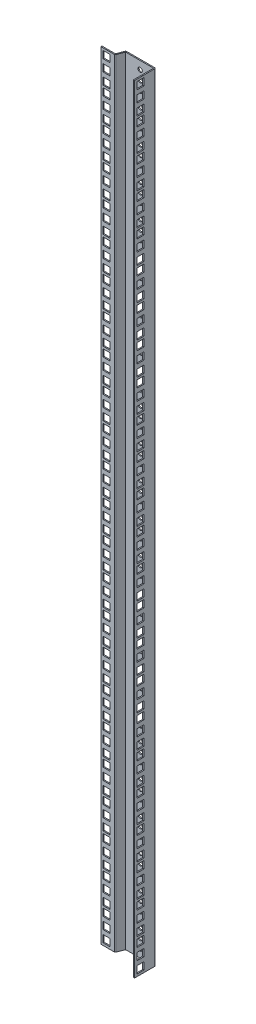
from build123d import *

# Parameters (mm, degrees)
EXTRUDE_1_DEPTH          = 1070
SKETCH_2_R               = 3
SKETCH_2_W               = 9.6
SKETCH_2_H               = 9.898426353
SKETCH_2_H_2             = 9.898426354
CUT_EXTRUDE_2_DEPTH      = 39
CUT_EXTRUDE_2_DEPTH_BACK = 84
SKETCH_4_W               = 9.6
SKETCH_4_H               = 9.898426353
SKETCH_4_H_2             = 9.898426354
CUT_EXTRUDE_3_DEPTH      = 26
CUT_EXTRUDE_3_DEPTH_BACK = 21


with BuildPart() as part:
    # 草图1 → 凸台-拉伸1 (new body)
    with BuildSketch(Plane(origin=(0, 0, 0), x_dir=(1, 0, 0), z_dir=(0, 1, 0))):
        with BuildLine():
            Line((-1.547342022, -0.717636551), (16.952657978, -0.71760263))
            ThreePointArc((16.952657978, -0.71760263), (17.80572902, -0.451398293), (18.356004933, 0.252726251))
            Line((18.356004933, 0.252726251), (21.952594506, 9.782387404))
            Line((21.952594506, 9.782387404), (60.452594506, 9.782387404))
            Line((60.452594506, 9.782387404), (60.452594506, -17.717612596))
            Line((60.452594506, -17.717612596), (61.952594506, -17.717612596))
            Line((61.952594506, -17.717612596), (61.952594506, 9.782387404))
            ThreePointArc((61.952594506, 9.782387404), (61.513254678, 10.843047575), (60.452594506, 11.282387404))
            Line((60.452594506, 11.282387404), (21.952594506, 11.282387404))
            ThreePointArc((21.952594506, 11.282387404), (21.099502117, 11.016175625), (20.549214051, 10.312031905))
            Line((20.549214051, 10.312031905), (16.952657978, 0.782363449))
            Line((16.952657978, 0.782363449), (-1.547342022, 0.782363449))
            Line((-1.547342022, 0.782363449), (-1.547342022, -0.717636551))
        make_face()
    extrude(amount=EXTRUDE_1_DEPTH)

    # 草图2 → 切除-拉伸2 (cut, two sides)
    with BuildSketch(Plane.XY.offset(-9.782387404)) as cut_extrude_2_sk:
        with Locations((41.952594506, 1046.275)):
            Circle(SKETCH_2_R)
        with Locations((41.952594506, 1058.775)):
            Circle(SKETCH_2_R)
        with Locations((41.952594506, 1033.775)):
            Circle(SKETCH_2_R)
        with Locations((41.952594506, 1001.825)):
            Circle(SKETCH_2_R)
        with Locations((41.952594506, 1014.325)):
            Circle(SKETCH_2_R)
        with Locations((41.952594506, 989.325)):
            Circle(SKETCH_2_R)
        with Locations((41.952594506, 957.375)):
            Circle(SKETCH_2_R)
        with Locations((41.952594506, 969.875)):
            Circle(SKETCH_2_R)
        with Locations((41.952594506, 944.875)):
            Circle(SKETCH_2_R)
        with Locations((41.952594506, 912.925)):
            Circle(SKETCH_2_R)
        with Locations((41.952594506, 925.425)):
            Circle(SKETCH_2_R)
        with Locations((41.952594506, 900.425)):
            Circle(SKETCH_2_R)
        with Locations((41.952594506, 868.475)):
            Circle(SKETCH_2_R)
        with Locations((41.952594506, 880.975)):
            Circle(SKETCH_2_R)
        with Locations((41.952594506, 855.975)):
            Circle(SKETCH_2_R)
        with Locations((41.952594506, 646.225)):
            Circle(SKETCH_2_R)
        with Locations((41.952594506, 658.725)):
            Circle(SKETCH_2_R)
        with Locations((41.952594506, 633.725)):
            Circle(SKETCH_2_R)
        with Locations((41.952594506, 601.775)):
            Circle(SKETCH_2_R)
        with Locations((41.952594506, 614.275)):
            Circle(SKETCH_2_R)
        with Locations((41.952594506, 589.275)):
            Circle(SKETCH_2_R)
        with Locations((41.952594506, 557.325)):
            Circle(SKETCH_2_R)
        with Locations((41.952594506, 569.825)):
            Circle(SKETCH_2_R)
        with Locations((41.952594506, 544.825)):
            Circle(SKETCH_2_R)
        with Locations((41.952594506, 512.875)):
            Circle(SKETCH_2_R)
        with Locations((41.952594506, 525.375)):
            Circle(SKETCH_2_R)
        with Locations((41.952594506, 500.375)):
            Circle(SKETCH_2_R)
        with Locations((41.952594506, 468.425)):
            Circle(SKETCH_2_R)
        with Locations((41.952594506, 480.925)):
            Circle(SKETCH_2_R)
        with Locations((41.952594506, 455.925)):
            Circle(SKETCH_2_R)
        with Locations((41.952594506, 246.175)):
            Circle(SKETCH_2_R)
        with Locations((41.952594506, 258.675)):
            Circle(SKETCH_2_R)
        with Locations((41.952594506, 233.675)):
            Circle(SKETCH_2_R)
        with Locations((41.952594506, 201.725)):
            Circle(SKETCH_2_R)
        with Locations((41.952594506, 214.225)):
            Circle(SKETCH_2_R)
        with Locations((41.952594506, 189.225)):
            Circle(SKETCH_2_R)
        with Locations((41.952594506, 157.275)):
            Circle(SKETCH_2_R)
        with Locations((41.952594506, 169.775)):
            Circle(SKETCH_2_R)
        with Locations((41.952594506, 144.775)):
            Circle(SKETCH_2_R)
        with Locations((41.952594506, 112.825)):
            Circle(SKETCH_2_R)
        with Locations((41.952594506, 125.325)):
            Circle(SKETCH_2_R)
        with Locations((41.952594506, 100.325)):
            Circle(SKETCH_2_R)
        with Locations((41.952594506, 68.375)):
            Circle(SKETCH_2_R)
        with Locations((41.952594506, 80.875)):
            Circle(SKETCH_2_R)
        with Locations((41.952594506, 55.875)):
            Circle(SKETCH_2_R)
        with Locations((41.952594506, 23.925)):
            Circle(SKETCH_2_R)
        with Locations((41.952594506, 36.425)):
            Circle(SKETCH_2_R)
        with Locations((41.952594506, 11.425)):
            Circle(SKETCH_2_R)
        with Locations((6.252657978, 662.000786823)):
            Rectangle(SKETCH_2_W, SKETCH_2_H)
        with Locations((6.252657978, 1062.050786823)):
            Rectangle(SKETCH_2_W, SKETCH_2_H)
        with Locations((6.252657978, 1017.600786824)):
            Rectangle(SKETCH_2_W, SKETCH_2_H)
        with Locations((6.252657978, 617.550786823)):
            Rectangle(SKETCH_2_W, SKETCH_2_H)
        with Locations((6.252657978, 1030.499213177)):
            Rectangle(SKETCH_2_W, SKETCH_2_H)
        with Locations((6.252657978, 1046.275)):
            Rectangle(SKETCH_2_W, SKETCH_2_H_2)
        with Locations((6.252657978, 884.250786823)):
            Rectangle(SKETCH_2_W, SKETCH_2_H)
        with Locations((6.252657978, 986.049213176)):
            Rectangle(SKETCH_2_W, SKETCH_2_H)
        with Locations((6.252657978, 1001.825)):
            Rectangle(SKETCH_2_W, SKETCH_2_H_2)
        with Locations((6.252657978, 973.150786824)):
            Rectangle(SKETCH_2_W, SKETCH_2_H)
        with Locations((6.252657978, 928.700786824)):
            Rectangle(SKETCH_2_W, SKETCH_2_H)
        with Locations((6.252657978, 941.599213177)):
            Rectangle(SKETCH_2_W, SKETCH_2_H)
        with Locations((6.252657978, 957.375)):
            Rectangle(SKETCH_2_W, SKETCH_2_H_2)
        with Locations((6.252657978, 897.149213177)):
            Rectangle(SKETCH_2_W, SKETCH_2_H)
        with Locations((6.252657978, 912.925)):
            Rectangle(SKETCH_2_W, SKETCH_2_H_2)
        with Locations((6.252657978, 839.800786823)):
            Rectangle(SKETCH_2_W, SKETCH_2_H)
        with Locations((6.252657978, 852.699213177)):
            Rectangle(SKETCH_2_W, SKETCH_2_H)
        with Locations((6.252657978, 868.475)):
            Rectangle(SKETCH_2_W, SKETCH_2_H_2)
        with Locations((6.252657978, 808.249213177)):
            Rectangle(SKETCH_2_W, SKETCH_2_H)
        with Locations((6.252657978, 824.025)):
            Rectangle(SKETCH_2_W, SKETCH_2_H_2)
        with BuildLine():
            Line((33.962594506, 832.025), (33.962594506, 816.025))
            ThreePointArc((33.962594506, 816.025), (41.952594506, 808.035), (49.942594506, 816.025))
            Line((49.942594506, 816.025), (49.942594506, 832.025))
            ThreePointArc((49.942594506, 832.025), (41.952594506, 840.015), (33.962594506, 832.025))
        make_face()
        with Locations((6.252657978, 795.350786824)):
            Rectangle(SKETCH_2_W, SKETCH_2_H)
        with Locations((6.252657978, 763.799213176)):
            Rectangle(SKETCH_2_W, SKETCH_2_H)
        with Locations((6.252657978, 779.575)):
            Rectangle(SKETCH_2_W, SKETCH_2_H_2)
        with BuildLine():
            Line((33.962594506, 787.575), (33.962594506, 771.575))
            ThreePointArc((33.962594506, 771.575), (41.952594506, 763.585), (49.942594506, 771.575))
            Line((49.942594506, 771.575), (49.942594506, 787.575))
            ThreePointArc((49.942594506, 787.575), (41.952594506, 795.565), (33.962594506, 787.575))
        make_face()
        with Locations((6.252657978, 750.900786824)):
            Rectangle(SKETCH_2_W, SKETCH_2_H)
        with Locations((6.252657978, 719.349213177)):
            Rectangle(SKETCH_2_W, SKETCH_2_H)
        with Locations((6.252657978, 735.125)):
            Rectangle(SKETCH_2_W, SKETCH_2_H_2)
        with BuildLine():
            Line((33.962594506, 743.125), (33.962594506, 727.125))
            ThreePointArc((33.962594506, 727.125), (41.952594506, 719.135), (49.942594506, 727.125))
            Line((49.942594506, 727.125), (49.942594506, 743.125))
            ThreePointArc((49.942594506, 743.125), (41.952594506, 751.115), (33.962594506, 743.125))
        make_face()
        with Locations((6.252657978, 706.450786824)):
            Rectangle(SKETCH_2_W, SKETCH_2_H)
        with Locations((6.252657978, 674.899213177)):
            Rectangle(SKETCH_2_W, SKETCH_2_H)
        with Locations((6.252657978, 690.675)):
            Rectangle(SKETCH_2_W, SKETCH_2_H_2)
        with BuildLine():
            Line((33.962594506, 698.675), (33.962594506, 682.675))
            ThreePointArc((33.962594506, 682.675), (41.952594506, 674.685), (49.942594506, 682.675))
            Line((49.942594506, 682.675), (49.942594506, 698.675))
            ThreePointArc((49.942594506, 698.675), (41.952594506, 706.665), (33.962594506, 698.675))
        make_face()
        with Locations((6.252657978, 630.449213177)):
            Rectangle(SKETCH_2_W, SKETCH_2_H)
        with Locations((6.252657978, 646.225)):
            Rectangle(SKETCH_2_W, SKETCH_2_H_2)
        with Locations((6.252657978, 484.200786824)):
            Rectangle(SKETCH_2_W, SKETCH_2_H)
        with Locations((6.252657978, 585.999213177)):
            Rectangle(SKETCH_2_W, SKETCH_2_H)
        with Locations((6.252657978, 601.775)):
            Rectangle(SKETCH_2_W, SKETCH_2_H_2)
        with Locations((6.252657978, 573.100786824)):
            Rectangle(SKETCH_2_W, SKETCH_2_H)
        with Locations((6.252657978, 528.650786824)):
            Rectangle(SKETCH_2_W, SKETCH_2_H)
        with Locations((6.252657978, 541.549213176)):
            Rectangle(SKETCH_2_W, SKETCH_2_H)
        with Locations((6.252657978, 557.325)):
            Rectangle(SKETCH_2_W, SKETCH_2_H_2)
        with Locations((6.252657978, 497.099213177)):
            Rectangle(SKETCH_2_W, SKETCH_2_H)
        with Locations((6.252657978, 512.875)):
            Rectangle(SKETCH_2_W, SKETCH_2_H_2)
        with Locations((6.252657978, 439.750786824)):
            Rectangle(SKETCH_2_W, SKETCH_2_H)
        with Locations((6.252657978, 452.649213177)):
            Rectangle(SKETCH_2_W, SKETCH_2_H)
        with Locations((6.252657978, 468.425)):
            Rectangle(SKETCH_2_W, SKETCH_2_H_2)
        with Locations((6.252657978, 408.199213177)):
            Rectangle(SKETCH_2_W, SKETCH_2_H)
        with Locations((6.252657978, 423.975)):
            Rectangle(SKETCH_2_W, SKETCH_2_H_2)
        with BuildLine():
            Line((33.962594506, 431.975), (33.962594506, 415.975))
            ThreePointArc((33.962594506, 415.975), (41.952594506, 407.985), (49.942594506, 415.975))
            Line((49.942594506, 415.975), (49.942594506, 431.975))
            ThreePointArc((49.942594506, 431.975), (41.952594506, 439.965), (33.962594506, 431.975))
        make_face()
        with Locations((6.252657978, 395.300786824)):
            Rectangle(SKETCH_2_W, SKETCH_2_H)
        with Locations((6.252657978, 363.749213177)):
            Rectangle(SKETCH_2_W, SKETCH_2_H)
        with Locations((6.252657978, 379.525)):
            Rectangle(SKETCH_2_W, SKETCH_2_H_2)
        with BuildLine():
            Line((33.962594506, 387.525), (33.962594506, 371.525))
            ThreePointArc((33.962594506, 371.525), (41.952594506, 363.535), (49.942594506, 371.525))
            Line((49.942594506, 371.525), (49.942594506, 387.525))
            ThreePointArc((49.942594506, 387.525), (41.952594506, 395.515), (33.962594506, 387.525))
        make_face()
        with Locations((6.252657978, 350.850786824)):
            Rectangle(SKETCH_2_W, SKETCH_2_H)
        with Locations((6.252657978, 319.299213177)):
            Rectangle(SKETCH_2_W, SKETCH_2_H)
        with Locations((6.252657978, 335.075)):
            Rectangle(SKETCH_2_W, SKETCH_2_H_2)
        with BuildLine():
            Line((33.962594506, 343.075), (33.962594506, 327.075))
            ThreePointArc((33.962594506, 327.075), (41.952594506, 319.085), (49.942594506, 327.075))
            Line((49.942594506, 327.075), (49.942594506, 343.075))
            ThreePointArc((49.942594506, 343.075), (41.952594506, 351.065), (33.962594506, 343.075))
        make_face()
        with Locations((6.252657978, 306.400786824)):
            Rectangle(SKETCH_2_W, SKETCH_2_H)
        with Locations((6.252657978, 274.849213177)):
            Rectangle(SKETCH_2_W, SKETCH_2_H)
        with Locations((6.252657978, 290.625)):
            Rectangle(SKETCH_2_W, SKETCH_2_H_2)
        with BuildLine():
            Line((33.962594506, 298.625), (33.962594506, 282.625))
            ThreePointArc((33.962594506, 282.625), (41.952594506, 274.635), (49.942594506, 282.625))
            Line((49.942594506, 282.625), (49.942594506, 298.625))
            ThreePointArc((49.942594506, 298.625), (41.952594506, 306.615), (33.962594506, 298.625))
        make_face()
        with Locations((6.252657978, 261.950786824)):
            Rectangle(SKETCH_2_W, SKETCH_2_H)
        with Locations((6.252657978, 217.500786824)):
            Rectangle(SKETCH_2_W, SKETCH_2_H)
        with Locations((6.252657978, 230.399213177)):
            Rectangle(SKETCH_2_W, SKETCH_2_H)
        with Locations((6.252657978, 246.175)):
            Rectangle(SKETCH_2_W, SKETCH_2_H_2)
        with Locations((6.252657978, 84.150786823)):
            Rectangle(SKETCH_2_W, SKETCH_2_H)
        with Locations((6.252657978, 185.949213176)):
            Rectangle(SKETCH_2_W, SKETCH_2_H)
        with Locations((6.252657978, 201.725)):
            Rectangle(SKETCH_2_W, SKETCH_2_H_2)
        with Locations((6.252657978, 173.050786824)):
            Rectangle(SKETCH_2_W, SKETCH_2_H)
        with Locations((6.252657978, 128.600786824)):
            Rectangle(SKETCH_2_W, SKETCH_2_H)
        with Locations((6.252657978, 141.499213177)):
            Rectangle(SKETCH_2_W, SKETCH_2_H)
        with Locations((6.252657978, 157.275)):
            Rectangle(SKETCH_2_W, SKETCH_2_H_2)
        with Locations((6.252657978, 97.049213177)):
            Rectangle(SKETCH_2_W, SKETCH_2_H)
        with Locations((6.252657978, 112.825)):
            Rectangle(SKETCH_2_W, SKETCH_2_H_2)
        with Locations((6.252657978, 39.700786824)):
            Rectangle(SKETCH_2_W, SKETCH_2_H)
        with Locations((6.252657978, 52.599213177)):
            Rectangle(SKETCH_2_W, SKETCH_2_H)
        with Locations((6.252657978, 68.375)):
            Rectangle(SKETCH_2_W, SKETCH_2_H_2)
        with Locations((6.252657978, 8.149213176)):
            Rectangle(SKETCH_2_W, SKETCH_2_H)
        with Locations((6.252657978, 23.925)):
            Rectangle(SKETCH_2_W, SKETCH_2_H_2)
    extrude(amount=CUT_EXTRUDE_2_DEPTH, mode=Mode.SUBTRACT)
    extrude(cut_extrude_2_sk.sketch, amount=-CUT_EXTRUDE_2_DEPTH_BACK, mode=Mode.SUBTRACT)

    # 草图4 → 切除-拉伸3 (cut, two sides)
    with BuildSketch(Plane(origin=(61.952594506, 0, 0), x_dir=(0, 0, -1), z_dir=(1, 0, 0))) as cut_extrude_3_sk:
        with Locations((-9.917612596, 662.000786823)):
            Rectangle(SKETCH_4_W, SKETCH_4_H)
        with Locations((-9.917612596, 1062.050786823)):
            Rectangle(SKETCH_4_W, SKETCH_4_H)
        with Locations((-9.917612596, 1017.600786824)):
            Rectangle(SKETCH_4_W, SKETCH_4_H)
        with Locations((-9.917612596, 617.550786823)):
            Rectangle(SKETCH_4_W, SKETCH_4_H)
        with Locations((-9.917612596, 1030.499213177)):
            Rectangle(SKETCH_4_W, SKETCH_4_H)
        with Locations((-9.917612596, 1046.275)):
            Rectangle(SKETCH_4_W, SKETCH_4_H_2)
        with Locations((-9.917612596, 884.250786823)):
            Rectangle(SKETCH_4_W, SKETCH_4_H)
        with Locations((-9.917612596, 986.049213176)):
            Rectangle(SKETCH_4_W, SKETCH_4_H)
        with Locations((-9.917612596, 1001.825)):
            Rectangle(SKETCH_4_W, SKETCH_4_H_2)
        with Locations((-9.917612596, 973.150786824)):
            Rectangle(SKETCH_4_W, SKETCH_4_H)
        with Locations((-9.917612596, 928.700786824)):
            Rectangle(SKETCH_4_W, SKETCH_4_H)
        with Locations((-9.917612596, 941.599213177)):
            Rectangle(SKETCH_4_W, SKETCH_4_H)
        with Locations((-9.917612596, 957.375)):
            Rectangle(SKETCH_4_W, SKETCH_4_H_2)
        with Locations((-9.917612596, 897.149213177)):
            Rectangle(SKETCH_4_W, SKETCH_4_H)
        with Locations((-9.917612596, 912.925)):
            Rectangle(SKETCH_4_W, SKETCH_4_H_2)
        with Locations((-9.917612596, 839.800786823)):
            Rectangle(SKETCH_4_W, SKETCH_4_H)
        with Locations((-9.917612596, 852.699213177)):
            Rectangle(SKETCH_4_W, SKETCH_4_H)
        with Locations((-9.917612596, 868.475)):
            Rectangle(SKETCH_4_W, SKETCH_4_H_2)
        with Locations((-9.917612596, 808.249213177)):
            Rectangle(SKETCH_4_W, SKETCH_4_H)
        with Locations((-9.917612596, 824.025)):
            Rectangle(SKETCH_4_W, SKETCH_4_H_2)
        with Locations((-9.917612596, 795.350786824)):
            Rectangle(SKETCH_4_W, SKETCH_4_H)
        with Locations((-9.917612596, 763.799213176)):
            Rectangle(SKETCH_4_W, SKETCH_4_H)
        with Locations((-9.917612596, 779.575)):
            Rectangle(SKETCH_4_W, SKETCH_4_H_2)
        with Locations((-9.917612596, 750.900786824)):
            Rectangle(SKETCH_4_W, SKETCH_4_H)
        with Locations((-9.917612596, 719.349213177)):
            Rectangle(SKETCH_4_W, SKETCH_4_H)
        with Locations((-9.917612596, 735.125)):
            Rectangle(SKETCH_4_W, SKETCH_4_H_2)
        with Locations((-9.917612596, 706.450786824)):
            Rectangle(SKETCH_4_W, SKETCH_4_H)
        with Locations((-9.917612596, 674.899213177)):
            Rectangle(SKETCH_4_W, SKETCH_4_H)
        with Locations((-9.917612596, 690.675)):
            Rectangle(SKETCH_4_W, SKETCH_4_H_2)
        with Locations((-9.917612596, 630.449213177)):
            Rectangle(SKETCH_4_W, SKETCH_4_H)
        with Locations((-9.917612596, 646.225)):
            Rectangle(SKETCH_4_W, SKETCH_4_H_2)
        with Locations((-9.917612596, 484.200786824)):
            Rectangle(SKETCH_4_W, SKETCH_4_H)
        with Locations((-9.917612596, 585.999213177)):
            Rectangle(SKETCH_4_W, SKETCH_4_H)
        with Locations((-9.917612596, 601.775)):
            Rectangle(SKETCH_4_W, SKETCH_4_H_2)
        with Locations((-9.917612596, 573.100786824)):
            Rectangle(SKETCH_4_W, SKETCH_4_H)
        with Locations((-9.917612596, 528.650786824)):
            Rectangle(SKETCH_4_W, SKETCH_4_H)
        with Locations((-9.917612596, 541.549213176)):
            Rectangle(SKETCH_4_W, SKETCH_4_H)
        with Locations((-9.917612596, 557.325)):
            Rectangle(SKETCH_4_W, SKETCH_4_H_2)
        with Locations((-9.917612596, 497.099213177)):
            Rectangle(SKETCH_4_W, SKETCH_4_H)
        with Locations((-9.917612596, 512.875)):
            Rectangle(SKETCH_4_W, SKETCH_4_H_2)
        with Locations((-9.917612596, 439.750786824)):
            Rectangle(SKETCH_4_W, SKETCH_4_H)
        with Locations((-9.917612596, 452.649213177)):
            Rectangle(SKETCH_4_W, SKETCH_4_H)
        with Locations((-9.917612596, 468.425)):
            Rectangle(SKETCH_4_W, SKETCH_4_H_2)
        with Locations((-9.917612596, 408.199213177)):
            Rectangle(SKETCH_4_W, SKETCH_4_H)
        with Locations((-9.917612596, 423.975)):
            Rectangle(SKETCH_4_W, SKETCH_4_H_2)
        with Locations((-9.917612596, 395.300786824)):
            Rectangle(SKETCH_4_W, SKETCH_4_H)
        with Locations((-9.917612596, 363.749213177)):
            Rectangle(SKETCH_4_W, SKETCH_4_H)
        with Locations((-9.917612596, 379.525)):
            Rectangle(SKETCH_4_W, SKETCH_4_H_2)
        with Locations((-9.917612596, 350.850786824)):
            Rectangle(SKETCH_4_W, SKETCH_4_H)
        with Locations((-9.917612596, 319.299213177)):
            Rectangle(SKETCH_4_W, SKETCH_4_H)
        with Locations((-9.917612596, 335.075)):
            Rectangle(SKETCH_4_W, SKETCH_4_H_2)
        with Locations((-9.917612596, 306.400786824)):
            Rectangle(SKETCH_4_W, SKETCH_4_H)
        with Locations((-9.917612596, 274.849213177)):
            Rectangle(SKETCH_4_W, SKETCH_4_H)
        with Locations((-9.917612596, 290.625)):
            Rectangle(SKETCH_4_W, SKETCH_4_H_2)
        with Locations((-9.917612596, 261.950786824)):
            Rectangle(SKETCH_4_W, SKETCH_4_H)
        with Locations((-9.917612596, 217.500786824)):
            Rectangle(SKETCH_4_W, SKETCH_4_H)
        with Locations((-9.917612596, 230.399213177)):
            Rectangle(SKETCH_4_W, SKETCH_4_H)
        with Locations((-9.917612596, 246.175)):
            Rectangle(SKETCH_4_W, SKETCH_4_H_2)
        with Locations((-9.917612596, 84.150786823)):
            Rectangle(SKETCH_4_W, SKETCH_4_H)
        with Locations((-9.917612596, 185.949213176)):
            Rectangle(SKETCH_4_W, SKETCH_4_H)
        with Locations((-9.917612596, 201.725)):
            Rectangle(SKETCH_4_W, SKETCH_4_H_2)
        with Locations((-9.917612596, 173.050786824)):
            Rectangle(SKETCH_4_W, SKETCH_4_H)
        with Locations((-9.917612596, 128.600786824)):
            Rectangle(SKETCH_4_W, SKETCH_4_H)
        with Locations((-9.917612596, 141.499213177)):
            Rectangle(SKETCH_4_W, SKETCH_4_H)
        with Locations((-9.917612596, 157.275)):
            Rectangle(SKETCH_4_W, SKETCH_4_H_2)
        with Locations((-9.917612596, 97.049213177)):
            Rectangle(SKETCH_4_W, SKETCH_4_H)
        with Locations((-9.917612596, 112.825)):
            Rectangle(SKETCH_4_W, SKETCH_4_H_2)
        with Locations((-9.917612596, 39.700786824)):
            Rectangle(SKETCH_4_W, SKETCH_4_H)
        with Locations((-9.917612596, 52.599213177)):
            Rectangle(SKETCH_4_W, SKETCH_4_H)
        with Locations((-9.917612596, 68.375)):
            Rectangle(SKETCH_4_W, SKETCH_4_H_2)
        with Locations((-9.917612596, 8.149213176)):
            Rectangle(SKETCH_4_W, SKETCH_4_H)
        with Locations((-9.917612596, 23.925)):
            Rectangle(SKETCH_4_W, SKETCH_4_H_2)
    extrude(amount=CUT_EXTRUDE_3_DEPTH, mode=Mode.SUBTRACT)
    extrude(cut_extrude_3_sk.sketch, amount=-CUT_EXTRUDE_3_DEPTH_BACK, mode=Mode.SUBTRACT)


solid = part.part
